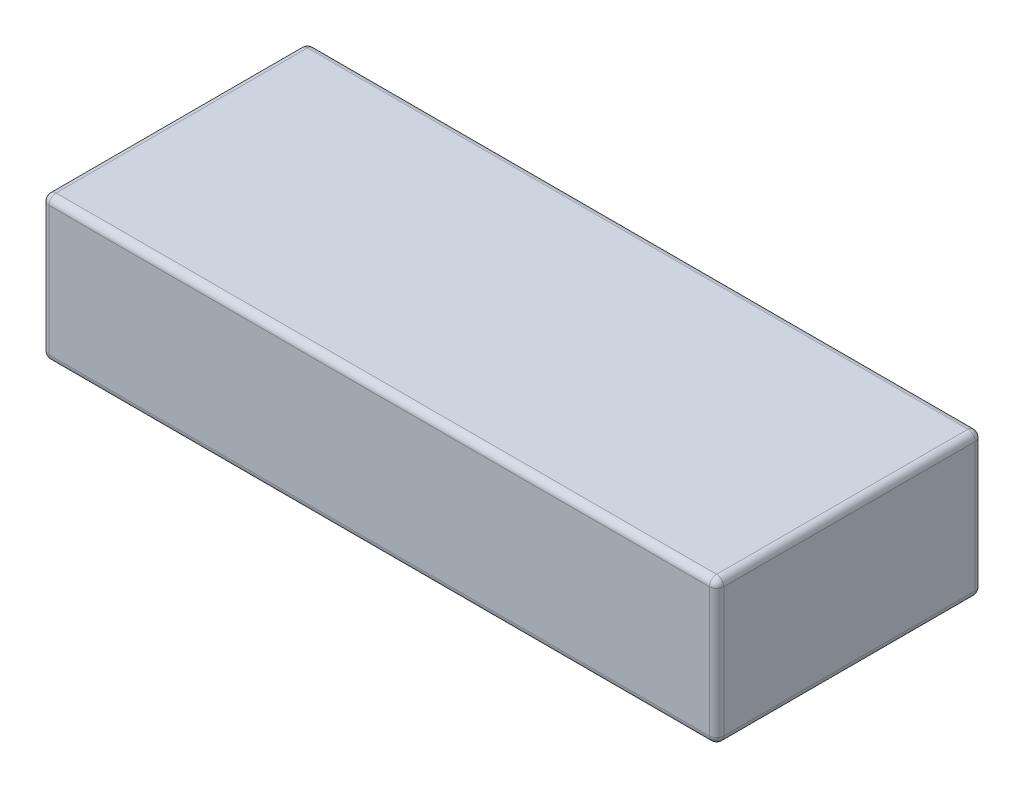
from build123d import *

# Parameters (mm, degrees)
CROQUIS1_W              = 94
CROQUIS1_H              = 37
SALIENTE_EXTRUIR1_DEPTH = 20
REDONDEO1_R             = 1


with BuildPart() as part:
    # Croquis1 → Saliente-Extruir1 (new body)
    with BuildSketch(Plane(origin=(0, 0, 0), x_dir=(1, 0, 0), z_dir=(0, 1, 0))):
        with Locations((47, 18.5)):
            Rectangle(CROQUIS1_W, CROQUIS1_H)
    extrude(amount=SALIENTE_EXTRUIR1_DEPTH)

    # Redondeo1
    redondeo1_edges = [part.edges().sort_by_distance(p)[0] for p in [
        (94, 20, -18.5),
        (47, 20, -37),
        (0, 20, -18.5),
        (47, 0, -37),
        (94, 0, -18.5),
        (47, 0, 0),
        (0, 0, -18.5),
        (0, 10, -37),
        (94, 10, -37),
        (94, 10, 0),
        (0, 10, 0),
        (47, 20, 0),
    ]]
    fillet(redondeo1_edges, radius=REDONDEO1_R)


solid = part.part
